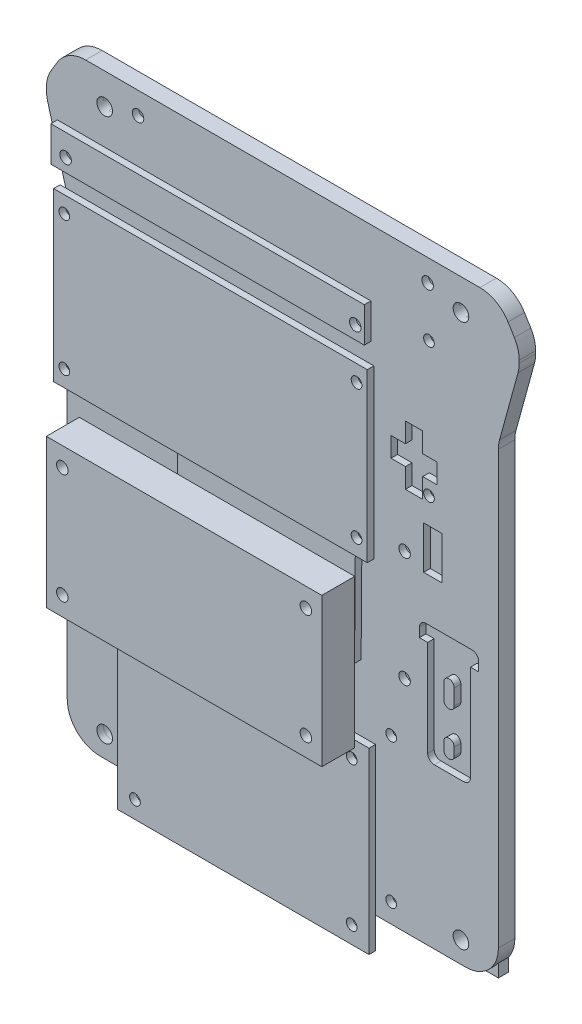
from build123d import *

# Parameters (mm, degrees)
BOSS_EXTRUDE2_DEPTH  = 5
SKETCH4_R            = 1
BATTERY_PACK_DEPTH   = 195.781730457
SKETCH5_R            = 1.625
MOTOR_MOUNTS_DEPTH   = 195.781730457
SKETCH6_R            = 1.625
MTR_CLTR_DEPTH       = 195.781730457
CASTER_R             = 1.625
FRONT_WHEEL_DEPTH    = 195.781730457
ANLG_CTLR_R          = 1.625
ANLG_CTLR_1_DEPTH    = 195.781730457
BRD_BOARD_R          = 1.75
BREADBOARD_DEPTH     = 195.781730457
TOP_PLATE_R          = 2.3749
CUT_EXTRUDE3_DEPTH   = 195.781730457
TOP_PLATE_3_W        = 127
TOP_PLATE_3_H        = 177.8
TOP_PLATE_3_R        = 6.35
TOP_PLATE_3_R_2      = 2.3749
BOSS_EXTRUDE3_DEPTH  = 3
SENSOR_BOARD_R       = 1.75
SENSOR_DEPTH         = 195.781730457
SKETCH18_W           = 5.6
SKETCH18_H           = 13
CUT_EXTRUDE5_DEPTH   = 195.781730457
CUT_EXTRUDE6_DEPTH   = 195.781730457
BOSS_EXTRUDE5_START  = 10
SKETCH16_3_W         = 57.15
SKETCH16_3_H         = 23.114
SKETCH16_3_R         = 1.5875
BOSS_EXTRUDE5_DEPTH  = 2
BOSS_EXTRUDE6_START  = 10
SKETCH10_3_R         = 1.75
BOSS_EXTRUDE6_DEPTH  = 2
BOSS_EXTRUDE7_START  = 10
SKETCH6_2_W          = 76.36
SKETCH6_2_H          = 54.3
SKETCH6_2_R          = 1.625
BOSS_EXTRUDE7_DEPTH  = 2
BOSS_EXTRUDE8_START  = 10
BOSS_EXTRUDE8_DEPTH  = 5.4
BOSS_EXTRUDE9_START  = 20
SKETCH8_2_W          = 95.3
SKETCH8_2_H          = 50.81
SKETCH8_2_R          = 1.625
BOSS_EXTRUDE9_DEPTH  = 2
BOSS_EXTRUDE10_START = 20
SKETCH9_3_W          = 83.7
SKETCH9_3_H          = 45.1
SKETCH9_3_R          = 1.75
BOSS_EXTRUDE10_DEPTH = 10
BOSS_EXTRUDE11_START = -10
SKETCH7_3_W          = 38
SKETCH7_3_H          = 33
SKETCH7_3_R          = 1.625
BOSS_EXTRUDE11_DEPTH = 2
BOSS_EXTRUDE12_START = 20
SENSOR_BOARD_3_W     = 95.25
SENSOR_BOARD_3_H     = 10.65
SENSOR_BOARD_3_R     = 1.75
BOSS_EXTRUDE12_DEPTH = 2
FPGA_R               = 1.75
CUT_EXTRUDE10_DEPTH  = 198.838122008


with BuildPart() as part:
    # Outline1 → Boss-Extrude2 (new body)
    with BuildSketch(Plane.XY):
        with BuildLine():
            Line((-65.5, 141.268437099), (-65.5, 10))
            ThreePointArc((-65.5, 10), (-62.571067812, 2.928932188), (-55.5, 0))
            Line((-55.5, 0), (55.5, 0))
            ThreePointArc((55.5, 0), (62.571067812, 2.928932188), (65.5, 10))
            Line((65.5, 10), (65.5, 141.268437099))
            ThreePointArc((65.5, 141.268437099), (65.589402556, 142.602625355), (65.856011661, 143.912957643))
            Line((65.856011661, 143.912957643), (71.465198975, 164.368437622))
            ThreePointArc((71.465198975, 164.368437622), (71.731808079, 165.67876991), (71.821210635, 167.012958167))
            Line((71.821210635, 167.012958167), (71.821210635, 167.847824973))
            ThreePointArc((71.821210635, 167.847824973), (71.446110508, 170.560996999), (70.348950147, 173.070626791))
            Line((70.348950147, 173.070626791), (68.425788167, 176.210746783))
            ThreePointArc((68.425788167, 176.210746783), (64.785378285, 179.712279271), (59.898048656, 180.987944965))
            Line((59.898048656, 180.987944965), (-59.898048655, 180.987944965))
            ThreePointArc((-59.898048655, 180.987944965), (-64.785378285, 179.712279271), (-68.425788167, 176.210746783))
            Line((-68.425788167, 176.210746783), (-70.348950147, 173.070626791))
            ThreePointArc((-70.348950147, 173.070626791), (-71.446110508, 170.560996999), (-71.821210635, 167.847824973))
            Line((-71.821210635, 167.847824973), (-71.821210635, 167.012958167))
            ThreePointArc((-71.821210635, 167.012958167), (-71.731808079, 165.67876991), (-71.465198975, 164.368437622))
            Line((-71.465198975, 164.368437622), (-65.856011661, 143.912957643))
            ThreePointArc((-65.856011661, 143.912957643), (-65.589402556, 142.602625355), (-65.5, 141.268437099))
        make_face()
    extrude(amount=BOSS_EXTRUDE2_DEPTH)

    # Sketch4 → Battery Pack (cut, through all)
    with BuildSketch(Plane.XY.offset(5)):
        with Locations((0, 105.731791241)):
            Circle(SKETCH4_R)
        with Locations((0, 61.131791241)):
            Circle(SKETCH4_R)
        with Locations((0, 55.681791241)):
            Circle(SKETCH4_R)
        with Locations((0, 111.181791241)):
            Circle(SKETCH4_R)
    extrude(amount=-BATTERY_PACK_DEPTH, mode=Mode.SUBTRACT)

    # Sketch5 → Motor mounts (cut, through all)
    with BuildSketch(Plane.XY.offset(5)):
        Polygon((37.25, 116.577082215), (42.5, 116.577082215), (42.5, 122.577082215), (46.875, 122.577082215), (46.875, 128.577082215), (42.5, 128.577082215), (42.5, 134.577082215), (37.25, 134.577082215), (37.25, 128.577082215), (32.875, 128.577082215), (32.875, 122.577082215), (37.25, 122.577082215), align=None)
        Polygon((-37.25, 134.577082215), (-37.25, 128.577082215), (-32.875, 128.577082215), (-32.875, 122.577082215), (-37.25, 122.577082215), (-37.25, 116.577082215), (-42.5, 116.577082215), (-42.5, 122.577082215), (-46.875, 122.577082215), (-46.875, 128.577082215), (-42.5, 128.577082215), (-42.5, 134.577082215), align=None)
        with Locations((-45.5, 108.277082215)):
            Circle(SKETCH5_R)
        with Locations((-45.5, 99.777082215)):
            Circle(SKETCH5_R)
        with Locations(Location((45.5, 99.777082215, 0), (0, 0, 180))):
            Circle(SKETCH5_R)
        with Locations(Location((45.5, 108.277082215, 0), (0, 0, 180))):
            Circle(SKETCH5_R)
    extrude(amount=-MOTOR_MOUNTS_DEPTH, mode=Mode.SUBTRACT)

    # Sketch6 → mtr_cltr (cut, through all)
    with BuildSketch(Plane.XY.offset(5)):
        with Locations((-32.93, 49.68)):
            Circle(SKETCH6_R)
        with Locations((-32.93, 5.88)):
            Circle(SKETCH6_R)
        with Locations((32.93, 5.88)):
            Circle(SKETCH6_R)
        with Locations((32.93, 49.68)):
            Circle(SKETCH6_R)
    extrude(amount=-MTR_CLTR_DEPTH, mode=Mode.SUBTRACT)

    # Caster → Front Wheel (cut, through all)
    with BuildSketch(Plane.XY.offset(5)):
        with Locations((-15.5, 35.5)):
            Circle(CASTER_R)
        with Locations((15.5, 35.5)):
            Circle(CASTER_R)
        with Locations((15.5, 12)):
            Circle(CASTER_R)
        with Locations((-15.5, 12)):
            Circle(CASTER_R)
    extrude(amount=-FRONT_WHEEL_DEPTH, mode=Mode.SUBTRACT)

    # anlg_ctlr → anlg_ctlr.1 (cut, through all)
    with BuildSketch(Plane.XY.offset(5)):
        with Locations((-44.4, 118.467082215)):
            Circle(ANLG_CTLR_R)
        with Locations((44.4, 159.277082215)):
            Circle(ANLG_CTLR_R)
        with Locations((44.4, 118.467082215)):
            Circle(ANLG_CTLR_R)
        with Locations((-44.4, 159.277082215)):
            Circle(ANLG_CTLR_R)
    extrude(amount=-ANLG_CTLR_1_DEPTH, mode=Mode.SUBTRACT)

    # brd_board → Breadboard (cut, through all)
    with BuildSketch(Plane.XY.offset(5)):
        with Locations((-37, 66.687944965)):
            Circle(BRD_BOARD_R)
        with Locations((-37, 100.187944965)):
            Circle(BRD_BOARD_R)
        with Locations((37, 100.187944965)):
            Circle(BRD_BOARD_R)
        with Locations((37, 66.687944965)):
            Circle(BRD_BOARD_R)
    extrude(amount=-BREADBOARD_DEPTH, mode=Mode.SUBTRACT)

    # Top PlaTE → Cut-Extrude3 (cut, through all)
    with BuildSketch(Plane.XY):
        with Locations((54.125, 6.474265411)):
            Circle(TOP_PLATE_R)
        with Locations((-54.125, 171.574265411)):
            Circle(TOP_PLATE_R)
        with Locations((54.125, 171.574265411)):
            Circle(TOP_PLATE_R)
        with Locations((-54.125, 6.474265411)):
            Circle(TOP_PLATE_R)
    extrude(amount=CUT_EXTRUDE3_DEPTH, mode=Mode.SUBTRACT)

    # Sensor Board → Sensor (cut, through all)
    with BuildSketch(Plane.XY.offset(5)):
        with Locations((-44, 174.275082215)):
            Circle(SENSOR_BOARD_R)
        with Locations((44, 174.275082215)):
            Circle(SENSOR_BOARD_R)
    extrude(amount=-SENSOR_DEPTH, mode=Mode.SUBTRACT)

    # Sketch18 → Cut-Extrude5 (cut, through all)
    with BuildSketch(Plane.XY):
        with Locations((-45.6, 104.027082215)):
            Rectangle(SKETCH18_W, SKETCH18_H)
        with Locations((45.6, 104.027082215)):
            Rectangle(SKETCH18_W, SKETCH18_H)
    extrude(amount=CUT_EXTRUDE5_DEPTH, mode=Mode.SUBTRACT)

    # Sketch19 → Cut-Extrude6 (cut, through all)
    with BuildSketch(Plane.XY):
        with BuildLine():
            Line((-59.5, 79.681962253), (-57, 79.681962253))
            Line((-57, 79.681962253), (-57, 50.501962253))
            ThreePointArc((-57, 50.501962253), (-56.414213562, 49.087748691), (-55, 48.501962253))
            Line((-55, 48.501962253), (-46, 48.501962253))
            ThreePointArc((-46, 48.501962253), (-44.585786438, 49.087748691), (-44, 50.501962253))
            Line((-44, 50.501962253), (-44, 79.681962253))
            Line((-44, 79.681962253), (-41.5, 79.681962253))
            Line((-41.5, 79.681962253), (-41.5, 82.444462253))
            ThreePointArc((-41.5, 82.444462253), (-42.085786438, 83.858675816), (-43.5, 84.444462253))
            Line((-43.5, 84.444462253), (-57.5, 84.444462253))
            ThreePointArc((-57.5, 84.444462253), (-58.914213562, 83.858675816), (-59.5, 82.444462253))
            Line((-59.5, 82.444462253), (-59.5, 79.681962253))
        make_face()
        with BuildLine():
            Line((-48.9125, 71.749720756), (-48.9125, 67.001962253))
            ThreePointArc((-48.9125, 67.001962253), (-50.5, 65.414462253), (-52.0875, 67.001962253))
            Line((-52.0875, 67.001962253), (-52.0875, 71.749720756))
            ThreePointArc((-52.0875, 71.749720756), (-50.5, 73.337220756), (-48.9125, 71.749720756))
        make_face(mode=Mode.SUBTRACT)
        with BuildLine():
            ThreePointArc((-48.9125, 53.841962253), (-50.5, 52.254462253), (-52.0875, 53.841962253))
            Line((-52.0875, 53.841962253), (-52.0875, 56.15560019))
            ThreePointArc((-52.0875, 56.15560019), (-50.5, 57.74310019), (-48.9125, 56.15560019))
            Line((-48.9125, 56.15560019), (-48.9125, 53.841962253))
        make_face(mode=Mode.SUBTRACT)
        with BuildLine():
            ThreePointArc((43.5, 84.444462253), (42.085786438, 83.858675816), (41.5, 82.444462253))
            Line((41.5, 82.444462253), (41.5, 79.681962253))
            Line((41.5, 79.681962253), (44, 79.681962253))
            Line((44, 79.681962253), (44, 50.501962253))
            ThreePointArc((44, 50.501962253), (44.585786438, 49.087748691), (46, 48.501962253))
            Line((46, 48.501962253), (55, 48.501962253))
            ThreePointArc((55, 48.501962253), (56.414213562, 49.087748691), (57, 50.501962253))
            Line((57, 50.501962253), (57, 79.681962253))
            Line((57, 79.681962253), (59.5, 79.681962253))
            Line((59.5, 79.681962253), (59.5, 82.444462253))
            ThreePointArc((59.5, 82.444462253), (58.914213562, 83.858675816), (57.5, 84.444462253))
            Line((57.5, 84.444462253), (43.5, 84.444462253))
        make_face()
        with BuildLine():
            ThreePointArc((48.9125, 71.749720756), (50.5, 73.337220756), (52.0875, 71.749720756))
            Line((52.0875, 71.749720756), (52.0875, 67.001962253))
            ThreePointArc((52.0875, 67.001962253), (50.5, 65.414462253), (48.9125, 67.001962253))
            Line((48.9125, 67.001962253), (48.9125, 71.749720756))
        make_face(mode=Mode.SUBTRACT)
        with BuildLine():
            Line((52.0875, 56.15560019), (52.0875, 53.841962253))
            ThreePointArc((52.0875, 53.841962253), (50.5, 52.254462253), (48.9125, 53.841962253))
            Line((48.9125, 53.841962253), (48.9125, 56.15560019))
            ThreePointArc((48.9125, 56.15560019), (50.5, 57.74310019), (52.0875, 56.15560019))
        make_face(mode=Mode.SUBTRACT)
    extrude(amount=CUT_EXTRUDE6_DEPTH, mode=Mode.SUBTRACT)


with BuildPart() as body_2:
    # Top PlaTE_3 → Boss-Extrude3 (new body)
    with BuildSketch(Plane.XY):
        with Locations((0, 89.024265411)):
            Rectangle(TOP_PLATE_3_W, TOP_PLATE_3_H)
        with Locations((-53.34, 50.924265411)):
            Circle(TOP_PLATE_3_R, mode=Mode.SUBTRACT)
        with Locations((54.125, 6.474265411)):
            Circle(TOP_PLATE_3_R_2, mode=Mode.SUBTRACT)
        with Locations((-54.125, 171.574265411)):
            Circle(TOP_PLATE_3_R_2, mode=Mode.SUBTRACT)
        with Locations((54.125, 171.574265411)):
            Circle(TOP_PLATE_3_R_2, mode=Mode.SUBTRACT)
        with Locations((-54.125, 6.474265411)):
            Circle(TOP_PLATE_3_R_2, mode=Mode.SUBTRACT)
    extrude(amount=BOSS_EXTRUDE3_DEPTH)

    # FPGA → Cut-Extrude10 (cut, through all)
    with BuildSketch(Plane.XY):
        with Locations((-34, 169.658814415)):
            Circle(FPGA_R)
        with Locations((34, 169.658814415)):
            Circle(FPGA_R)
        with Locations((34, 101.658814415)):
            Circle(FPGA_R)
        with Locations((-34, 101.658814415)):
            Circle(FPGA_R)
    extrude(amount=CUT_EXTRUDE10_DEPTH, mode=Mode.SUBTRACT)


with BuildPart() as cut_extrude6_piece_1:
    # of the separate pieces the step leaves, piece 1, a body of its own (cut_extrude6_pieces)
    add(part.part.solids().sort_by_distance((-68.425788167, 176.210746783, 0))[0])


with BuildPart() as cut_extrude6_piece_2:
    # of the separate pieces the step leaves, piece 2, a body of its own (cut_extrude6_pieces)
    add(part.part.solids().sort_by_distance((-48.9125, 71.749720756, 0))[0])


with BuildPart() as cut_extrude6_piece_3:
    # of the separate pieces the step leaves, piece 3, a body of its own (cut_extrude6_pieces)
    add(part.part.solids().sort_by_distance((48.9125, 71.749720756, 0))[0])


with BuildPart() as cut_extrude6_piece_4:
    # of the separate pieces the step leaves, piece 4, a body of its own (cut_extrude6_pieces)
    add(part.part.solids().sort_by_distance((52.0875, 56.15560019, 0))[0])


with BuildPart() as cut_extrude6_piece_5:
    # of the separate pieces the step leaves, piece 5, a body of its own (cut_extrude6_pieces)
    add(part.part.solids().sort_by_distance((-48.9125, 53.841962253, 0))[0])


with BuildPart() as body_7:
    # Sketch16_3 → Boss-Extrude5 (new body)
    with BuildSketch(Plane.XY.offset(BOSS_EXTRUDE5_START)):
        with Locations((0, 36.625433673)):
            Rectangle(SKETCH16_3_W, SKETCH16_3_H)
        with Locations((-25.908, 45.007433673)):
            Circle(SKETCH16_3_R, mode=Mode.SUBTRACT)
        with Locations((25.908, 45.007433673)):
            Circle(SKETCH16_3_R, mode=Mode.SUBTRACT)
        with Locations((25.908, 28.243433673)):
            Circle(SKETCH16_3_R, mode=Mode.SUBTRACT)
        with Locations((-25.908, 28.243433673)):
            Circle(SKETCH16_3_R, mode=Mode.SUBTRACT)
    extrude(amount=BOSS_EXTRUDE5_DEPTH)


with BuildPart() as body_8:
    # Sketch10_3 → Boss-Extrude6 (new body)
    with BuildSketch(Plane.XY.offset(BOSS_EXTRUDE6_START)):
        Polygon((-25.211498717, 70.476976171), (-15.961785964, 70.404079055), (-16.011040772, 64.154273141), (-3.761421181, 64.057733717), (-3.712166372, 70.307539631), (15.787228079, 70.15386463), (15.771466541, 68.153926737), (24.771187057, 68.082999813), (24.786948596, 70.082937706), (28.786824381, 70.051414628), (29.306955155, 136.049365081), (26.557040553, 136.071037197), (23.703801948, 138.843609011), (-9.295173278, 139.103674398), (-12.191756114, 136.376417008), (-24.691367942, 136.474926624), align=None)
        with Locations((25.405144609, 85.078531515)):
            Circle(SKETCH10_3_R, mode=Mode.SUBTRACT)
        with Locations((-21.593395865, 85.448927673)):
            Circle(SKETCH10_3_R, mode=Mode.SUBTRACT)
        with Locations((-6.686016333, 137.083049486)):
            Circle(SKETCH10_3_R, mode=Mode.SUBTRACT)
        with Locations((21.813098635, 136.858447561)):
            Circle(SKETCH10_3_R, mode=Mode.SUBTRACT)
    extrude(amount=BOSS_EXTRUDE6_DEPTH)


with BuildPart() as body_9:
    # Sketch6_2 → Boss-Extrude7 (new body)
    with BuildSketch(Plane.XY.offset(5).offset(BOSS_EXTRUDE7_START)):
        with Locations((0, 27.78)):
            Rectangle(SKETCH6_2_W, SKETCH6_2_H)
        with Locations((-32.93, 49.68)):
            Circle(SKETCH6_2_R, mode=Mode.SUBTRACT)
        with Locations((32.93, 49.68)):
            Circle(SKETCH6_2_R, mode=Mode.SUBTRACT)
        with Locations((32.93, 5.88)):
            Circle(SKETCH6_2_R, mode=Mode.SUBTRACT)
        with Locations((-32.93, 5.88)):
            Circle(SKETCH6_2_R, mode=Mode.SUBTRACT)
    extrude(amount=BOSS_EXTRUDE7_DEPTH)


with BuildPart() as body_10:
    # Sketch19_3 → Boss-Extrude8 (new body)
    with BuildSketch(Plane.XY.offset(BOSS_EXTRUDE8_START)):
        with BuildLine():
            Line((-59.5, 79.681962253), (-57, 79.681962253))
            Line((-57, 79.681962253), (-57, 50.501962253))
            ThreePointArc((-57, 50.501962253), (-56.414213562, 49.087748691), (-55, 48.501962253))
            Line((-55, 48.501962253), (-46, 48.501962253))
            ThreePointArc((-46, 48.501962253), (-44.585786438, 49.087748691), (-44, 50.501962253))
            Line((-44, 50.501962253), (-44, 79.681962253))
            Line((-44, 79.681962253), (-41.5, 79.681962253))
            Line((-41.5, 79.681962253), (-41.5, 82.444462253))
            ThreePointArc((-41.5, 82.444462253), (-42.085786438, 83.858675816), (-43.5, 84.444462253))
            Line((-43.5, 84.444462253), (-57.5, 84.444462253))
            ThreePointArc((-57.5, 84.444462253), (-58.914213562, 83.858675816), (-59.5, 82.444462253))
            Line((-59.5, 82.444462253), (-59.5, 79.681962253))
        make_face()
        with BuildLine():
            Line((-48.9125, 71.749720756), (-48.9125, 67.001962253))
            ThreePointArc((-48.9125, 67.001962253), (-50.5, 65.414462253), (-52.0875, 67.001962253))
            Line((-52.0875, 67.001962253), (-52.0875, 71.749720756))
            ThreePointArc((-52.0875, 71.749720756), (-50.5, 73.337220756), (-48.9125, 71.749720756))
        make_face(mode=Mode.SUBTRACT)
        with BuildLine():
            ThreePointArc((-48.9125, 53.841962253), (-50.5, 52.254462253), (-52.0875, 53.841962253))
            Line((-52.0875, 53.841962253), (-52.0875, 56.15560019))
            ThreePointArc((-52.0875, 56.15560019), (-50.5, 57.74310019), (-48.9125, 56.15560019))
            Line((-48.9125, 56.15560019), (-48.9125, 53.841962253))
        make_face(mode=Mode.SUBTRACT)
    extrude(amount=BOSS_EXTRUDE8_DEPTH)


with BuildPart() as body_11:
    # Sketch8_2 → Boss-Extrude9 (new body)
    with BuildSketch(Plane.XY.offset(5).offset(BOSS_EXTRUDE9_START)):
        with Locations((0, 138.872082215)):
            Rectangle(SKETCH8_2_W, SKETCH8_2_H)
        with Locations((44.4, 118.467082215)):
            Circle(SKETCH8_2_R, mode=Mode.SUBTRACT)
        with Locations((-44.4, 118.467082215)):
            Circle(SKETCH8_2_R, mode=Mode.SUBTRACT)
        with Locations((-44.4, 159.277082215)):
            Circle(SKETCH8_2_R, mode=Mode.SUBTRACT)
        with Locations((44.4, 159.277082215)):
            Circle(SKETCH8_2_R, mode=Mode.SUBTRACT)
    extrude(amount=BOSS_EXTRUDE9_DEPTH)


with BuildPart() as body_12:
    # Sketch9_3 → Boss-Extrude10 (new body)
    with BuildSketch(Plane.XY.offset(5).offset(BOSS_EXTRUDE10_START)):
        with Locations((0, 83.437944965)):
            Rectangle(SKETCH9_3_W, SKETCH9_3_H)
        with Locations((37, 66.687944965)):
            Circle(SKETCH9_3_R, mode=Mode.SUBTRACT)
        with Locations((-37, 66.687944965)):
            Circle(SKETCH9_3_R, mode=Mode.SUBTRACT)
        with Locations((-37, 100.187944965)):
            Circle(SKETCH9_3_R, mode=Mode.SUBTRACT)
        with Locations((37, 100.187944965)):
            Circle(SKETCH9_3_R, mode=Mode.SUBTRACT)
    extrude(amount=BOSS_EXTRUDE10_DEPTH)


with BuildPart() as body_13:
    # Sketch7_3 → Boss-Extrude11 (new body)
    with BuildSketch(Plane.XY.offset(5).offset(BOSS_EXTRUDE11_START)):
        with Locations((0, 23.75)):
            Rectangle(SKETCH7_3_W, SKETCH7_3_H)
        with Locations((-15.5, 35.5)):
            Circle(SKETCH7_3_R, mode=Mode.SUBTRACT)
        with Locations((15.5, 35.5)):
            Circle(SKETCH7_3_R, mode=Mode.SUBTRACT)
        with Locations((15.5, 12)):
            Circle(SKETCH7_3_R, mode=Mode.SUBTRACT)
        with Locations((-15.5, 12)):
            Circle(SKETCH7_3_R, mode=Mode.SUBTRACT)
    extrude(amount=BOSS_EXTRUDE11_DEPTH)


with BuildPart() as body_14:
    # Sensor Board_3 → Boss-Extrude12 (new body)
    with BuildSketch(Plane.XY.offset(5).offset(BOSS_EXTRUDE12_START)):
        with Locations((-0.875, 175.600082215)):
            Rectangle(SENSOR_BOARD_3_W, SENSOR_BOARD_3_H)
        with Locations((-44, 174.275082215)):
            Circle(SENSOR_BOARD_3_R, mode=Mode.SUBTRACT)
        with Locations((44, 174.275082215)):
            Circle(SENSOR_BOARD_3_R, mode=Mode.SUBTRACT)
    extrude(amount=BOSS_EXTRUDE12_DEPTH)


solid = Compound([body_2.part, cut_extrude6_piece_1.part, cut_extrude6_piece_2.part, cut_extrude6_piece_3.part, cut_extrude6_piece_4.part, cut_extrude6_piece_5.part, body_7.part, body_8.part, body_9.part, body_10.part, body_11.part, body_12.part, body_13.part, body_14.part])
